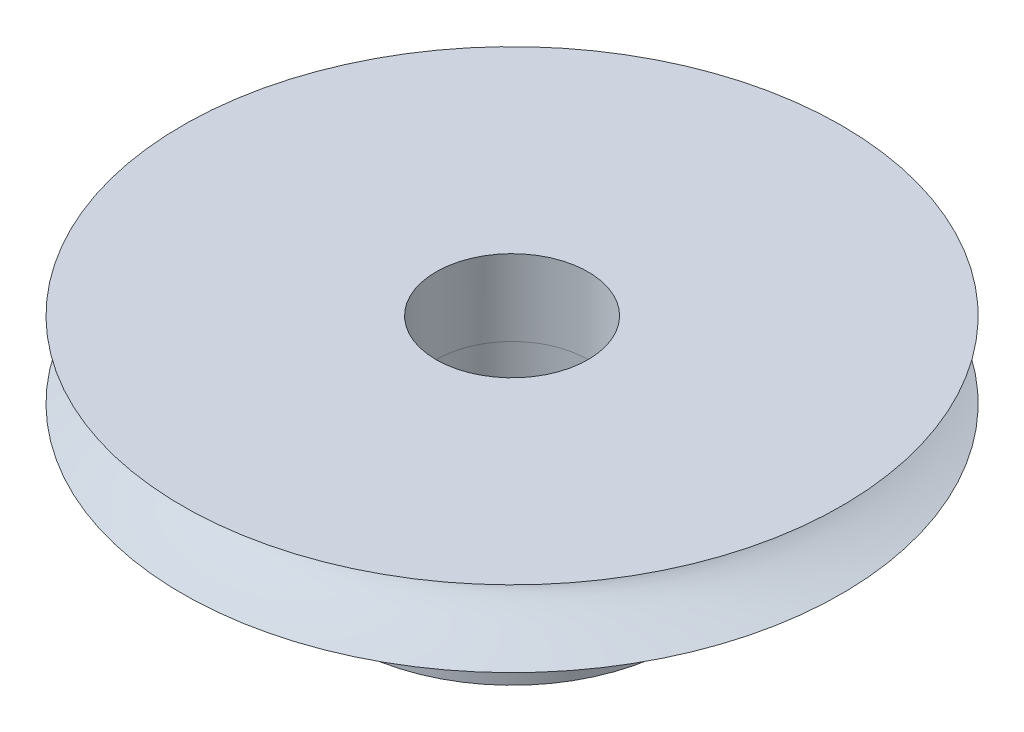
from build123d import *

# Parameters (mm, degrees)
SKETCH117_R           = 3
CUT_EXTRUDE4_DEPTH    = 3
SKETCH122_R           = 6.539767279
BOSS_EXTRUDE1_DEPTH   = 5
SKETCH123_R           = 3.0360463
CUT_EXTRUDE5_DEPTH    = 5
M2X0_4_TAPPED_HOLE1_D = 1.6


with BuildPart() as part:
    # Sketch9 → Revolve1 (revolve)
    with BuildSketch(Plane.XY):
        with BuildLine():
            Line((-4.703089141, -2.935363462), (8.296910859, -2.935363462))
            Line((8.296910859, -2.935363462), (8.296910859, 0.064636538))
            Line((8.296910859, 0.064636538), (-4.703089141, 0.064636538))
            add(Edge.make_bspline(
                [(-4.703089141, 0.064636538), (0.132127885, -1.294166307), (-4.703089141, -2.935363462)],
                knots=[0, 0, 0, 1, 1, 1], degree=2))
        make_face()
    revolve(axis=Axis((8.296910859, -2.935363462, 0), (0, 1, 0)))

    # Sketch117 → Cut-Extrude4 (cut)
    with BuildSketch(Plane(origin=(0, 0.064636538, 0), x_dir=(1, 0, 0), z_dir=(0, 1, 0))):
        with Locations((8.29691086, 0)):
            Circle(SKETCH117_R)
    extrude(amount=-CUT_EXTRUDE4_DEPTH, mode=Mode.SUBTRACT)

    # Sketch122 → Boss-Extrude1 (add)
    with BuildSketch(Plane(origin=(0, -2.935363462, 0), x_dir=(-1, 0, 0), z_dir=(0, -1, 0))):
        with Locations((-8.29691086, 0)):
            Circle(SKETCH122_R)
    extrude(amount=BOSS_EXTRUDE1_DEPTH)

    # Sketch123 → Cut-Extrude5 (cut)
    with BuildSketch(Plane(origin=(0, -2.935363462, 0), x_dir=(1, 0, 0), z_dir=(0, 1, 0))):
        with Locations((8.33295716, 0)):
            Circle(SKETCH123_R)
    extrude(amount=-CUT_EXTRUDE5_DEPTH, mode=Mode.SUBTRACT)

    # M2x0.4 Tapped Hole1 (through all)
    with Locations(Plane(origin=(1.815385484, -5.431649491, -0.870852953), x_dir=(0.133162682, 0, -0.991094193), z_dir=(-0.991094193, 0, -0.133162682))):
        with Locations((0, 0)):
            Hole(M2X0_4_TAPPED_HOLE1_D / 2)


solid = part.part
